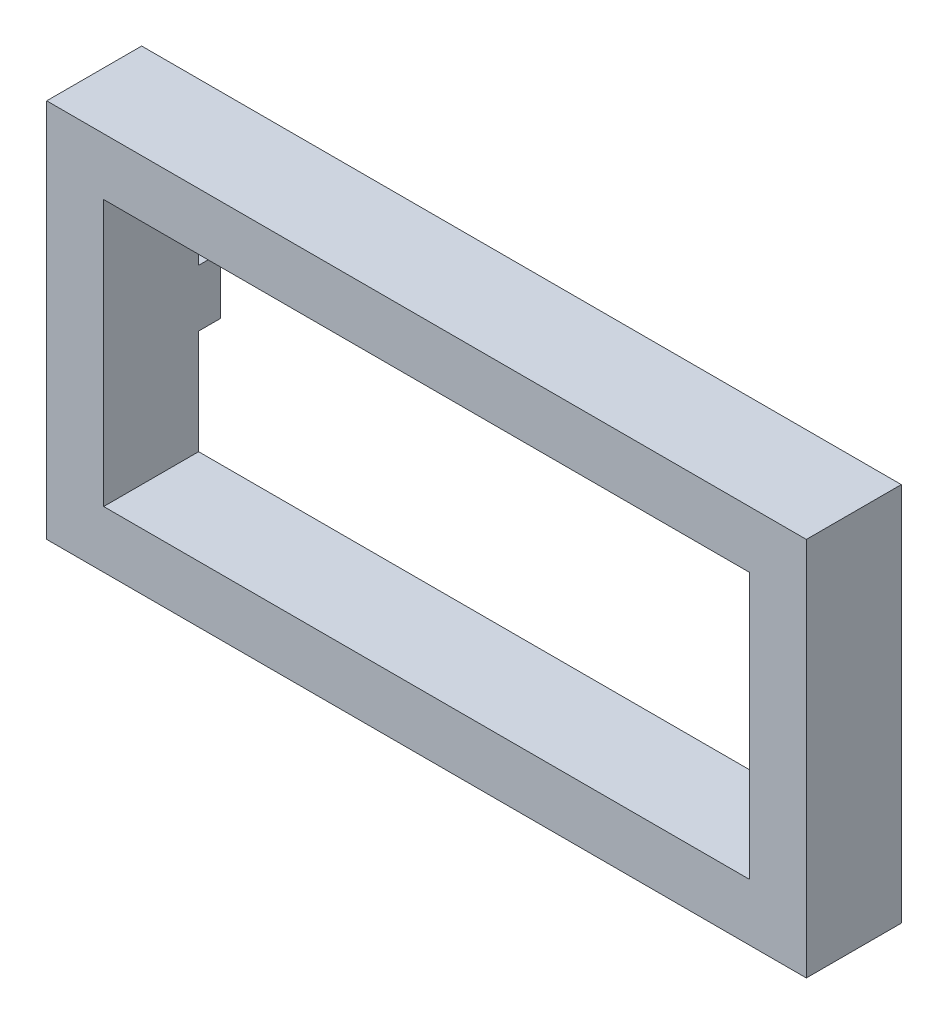
from build123d import *

# Parameters (mm, degrees)
SKETCH1_W           = 400
SKETCH1_H           = 200
SKETCH1_W_2         = 340
SKETCH1_H_2         = 140
BOSS_EXTRUDE1_DEPTH = 50
SKETCH2_W           = 15
SKETCH2_H           = 15
CUT_EXTRUDE1_DEPTH  = 40
SKETCH3_W           = 30
SKETCH3_H           = 30
SKETCH3_W_2         = 20
SKETCH3_H_2         = 20
BOSS_EXTRUDE2_DEPTH = 11.5


with BuildPart() as part:
    # Sketch1 → Boss-Extrude1 (new body)
    with BuildSketch(Plane.XY):
        with Locations((5.416666667, 0)):
            Rectangle(SKETCH1_W, SKETCH1_H)
        with Locations((5.416666667, 0)):
            Rectangle(SKETCH1_W_2, SKETCH1_H_2, mode=Mode.SUBTRACT)
    extrude(amount=BOSS_EXTRUDE1_DEPTH)

    # Sketch2 → Cut-Extrude1 (cut)
    with BuildSketch(Plane(origin=(0, 0, 0), x_dir=(-1, 0, 0), z_dir=(0, 0, -1))):
        with Locations((-77.916666667, 85)):
            Rectangle(SKETCH2_W, SKETCH2_H)
        with Locations((-77.916666667, -85)):
            Rectangle(SKETCH2_W, SKETCH2_H)
        Polygon((-197.916664047, 7.493396785), (-197.916664047, -7.506603215), (-182.916666667, -7.497737374), (-182.916666667, 7.502262626), align=None)
    extrude(amount=-CUT_EXTRUDE1_DEPTH, mode=Mode.SUBTRACT)

    # Sketch3 → Boss-Extrude2 (add)
    with BuildSketch(Plane(origin=(0, 0, 0), x_dir=(-1, 0, 0), z_dir=(0, 0, -1))):
        with Locations((179.583333333, 0)):
            Rectangle(SKETCH3_W, SKETCH3_H)
        with Locations((179.583333333, 0)):
            Rectangle(SKETCH3_W_2, SKETCH3_H_2, mode=Mode.SUBTRACT)
    extrude(amount=BOSS_EXTRUDE2_DEPTH)


solid = part.part
